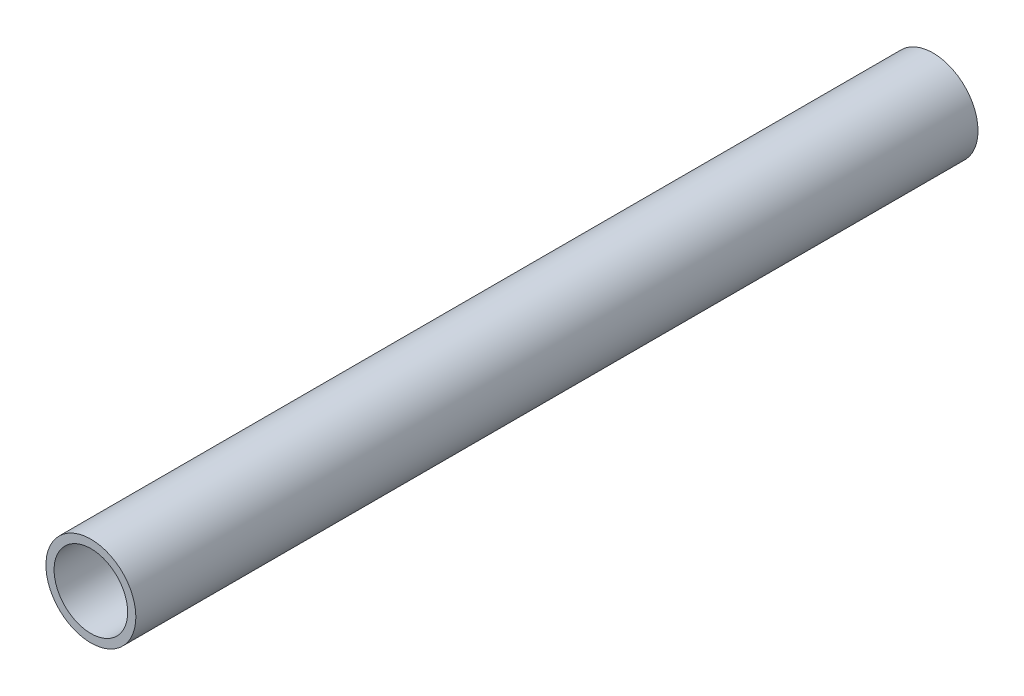
from build123d import *

# Parameters (mm, degrees)
SKETCH1_R           = 5.5
SKETCH1_R_2         = 4.5
BOSS_EXTRUDE1_DEPTH = 103


with BuildPart() as part:
    # Sketch1 → Boss-Extrude1 (new body)
    with BuildSketch(Plane.XY):
        Circle(SKETCH1_R)
        Circle(SKETCH1_R_2, mode=Mode.SUBTRACT)
    extrude(amount=BOSS_EXTRUDE1_DEPTH)


solid = part.part
